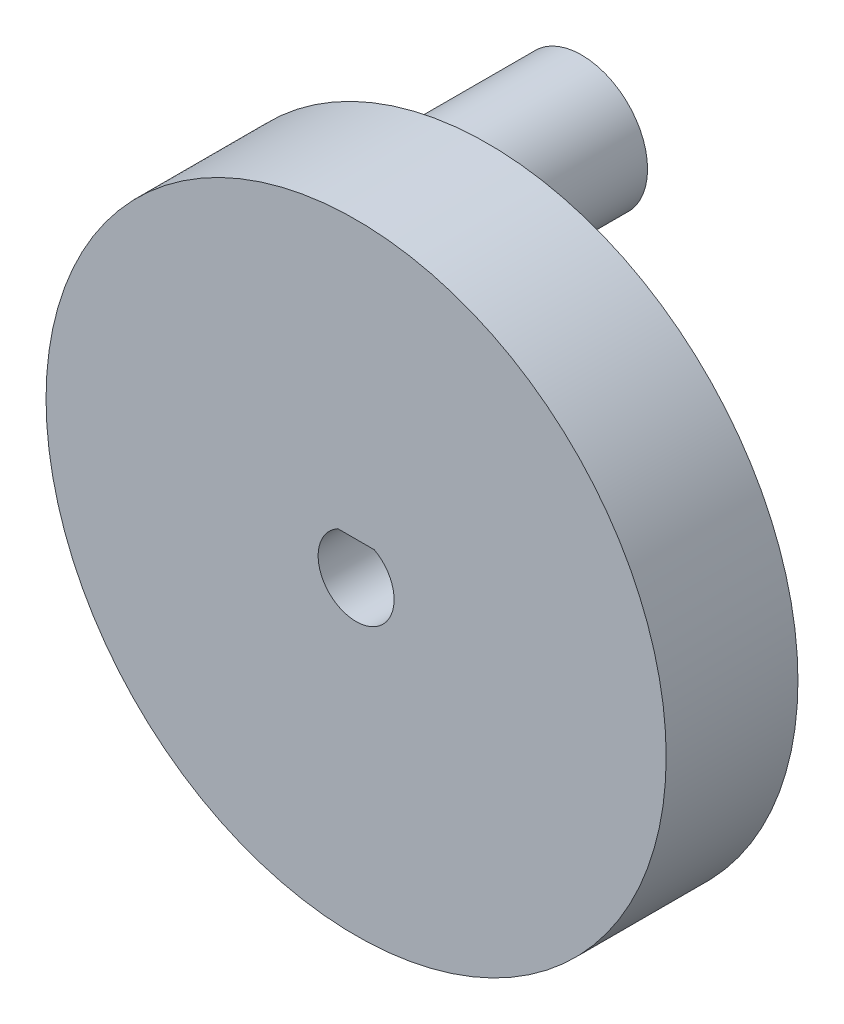
from build123d import *

# Parameters (mm, degrees)
CROQUIS1_R              = 20
SALIENTE_EXTRUIR1_DEPTH = 8.5
CROQUIS2_R              = 4.25
CROQUIS2_R_2            = 1.5
SALIENTE_EXTRUIR2_DEPTH = 15
CHAFL_N1_SIZE           = 1.5
CHAFL_N1_SIZE2          = 1.258649447


with BuildPart() as part:
    # Croquis1 → Saliente-Extruir1 (new body)
    with BuildSketch(Plane.XY):
        Circle(CROQUIS1_R)
        with BuildLine():
            Line((-1.174734012, 2.15), (1.174734012, 2.15))
            ThreePointArc((1.174734012, 2.15), (0, -2.45), (-1.174734012, 2.15))
        make_face(mode=Mode.SUBTRACT)
    extrude(amount=-SALIENTE_EXTRUIR1_DEPTH)

    # Croquis2 → Saliente-Extruir2 (add)
    with BuildSketch(Plane(origin=(0, 0, -8.5), x_dir=(-1, 0, 0), z_dir=(0, 0, -1))):
        with Locations((8.951131501, 8.725092827)):
            Circle(CROQUIS2_R)
        with Locations((8.951131501, 8.725092827)):
            Circle(CROQUIS2_R_2, mode=Mode.SUBTRACT)
    extrude(amount=SALIENTE_EXTRUIR2_DEPTH)

    # Chaflán1
    chafl_n1_edges = [part.edges().sort_by_distance(p)[0] for p in [
        (-4.701131501, 8.725092827, -8.5),
    ]]
    chafl_n1_side = [part.faces().sort_by_distance(p)[0] for p in [
        (-19.434314575, 0, -8.5),
    ]]
    chamfer(chafl_n1_edges, length=CHAFL_N1_SIZE, length2=CHAFL_N1_SIZE2, reference=chafl_n1_side[0])


solid = part.part
